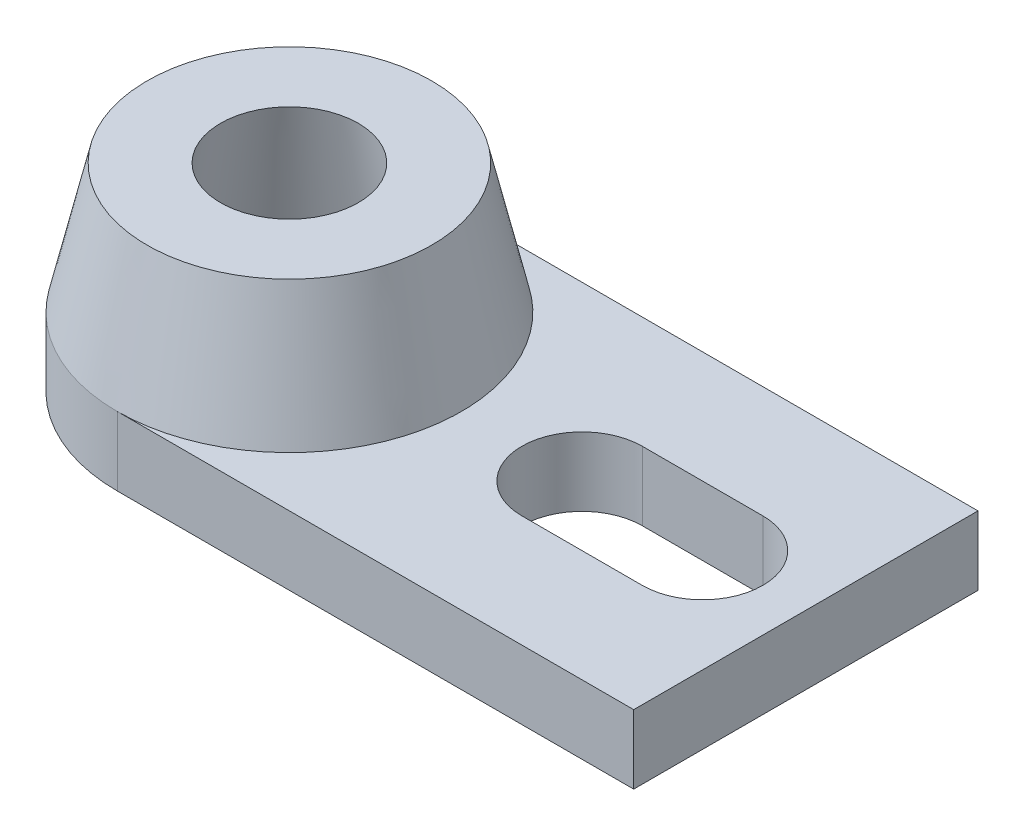
from build123d import *

# Parameters (mm, degrees)
SALIENTE_EXTRUIR1_DEPTH = 8


with BuildPart() as part:
    # Croquis2 → Saliente-Extruir1 (new body)
    with BuildSketch(Plane(origin=(0, 0, 0), x_dir=(1, 0, 0), z_dir=(0, 1, 0))):
        with BuildLine():
            Line((0, 0), (0, 40))
            Line((0, 40), (-60, 40))
            ThreePointArc((-60, 40), (-40, 20), (-60, 0))
            Line((-60, 0), (0, 0))
        make_face()
        with BuildLine():
            Line((-26, 27), (-12, 27))
            ThreePointArc((-12, 27), (-5, 20), (-12, 13))
            Line((-12, 13), (-26, 13))
            ThreePointArc((-26, 13), (-33, 20), (-26, 27))
        make_face(mode=Mode.SUBTRACT)
    extrude(amount=SALIENTE_EXTRUIR1_DEPTH)

    # Croquis6 → Revolución1 (revolve)
    with BuildSketch(Plane.XY.offset(-20)):
        Polygon((-72.055520556, 0), (-68, 23), (-76.536977133, 23), (-80, 8), (-80, 0), align=None)
    revolve(axis=Axis((-60, -24.638312798, -20), (0, 1, 0)))


solid = part.part
